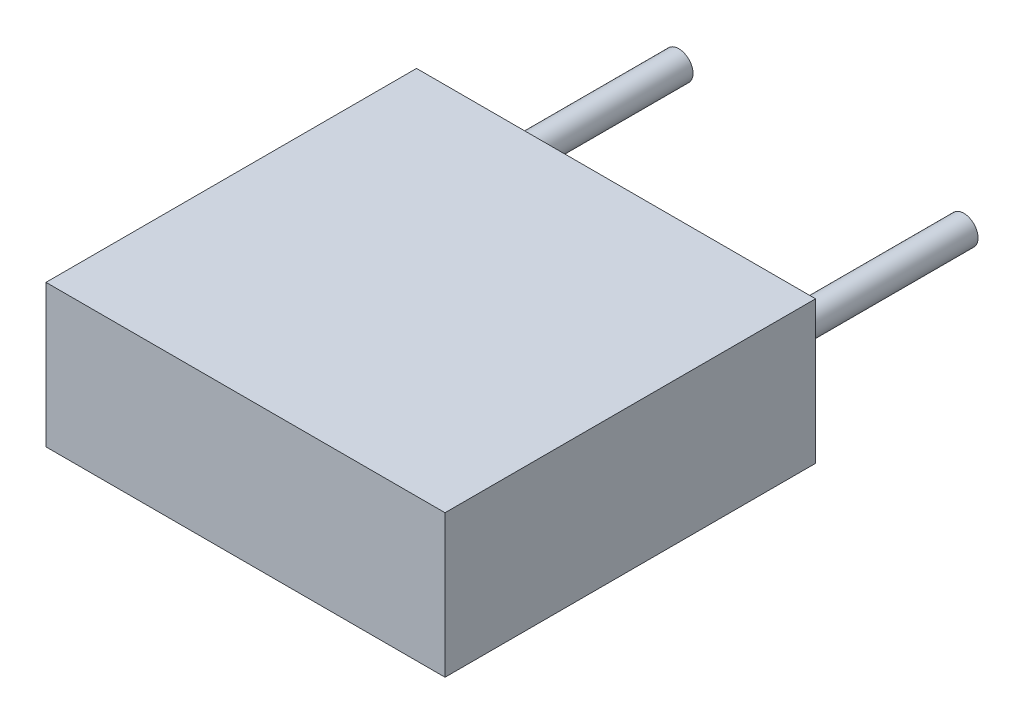
from build123d import *

# Parameters (mm, degrees)
ESQUISSE1_W        = 7
ESQUISSE1_H        = 2.5
BOSS_EXTRU_1_DEPTH = 6.5
ESQUISSE2_R        = 0.25
BOSS_EXTRU_2_DEPTH = 3.6


with BuildPart() as part:
    # Esquisse1 → Boss.-Extru.1 (new body)
    with BuildSketch(Plane.XY):
        Rectangle(ESQUISSE1_W, ESQUISSE1_H)
    extrude(amount=BOSS_EXTRU_1_DEPTH)

    # Esquisse2 → Boss.-Extru.2 (add)
    with BuildSketch(Plane(origin=(0, 0, 0), x_dir=(-1, 0, 0), z_dir=(0, 0, -1))):
        with Locations((-2.5, 0)):
            Circle(ESQUISSE2_R)
        with Locations((2.5, 0)):
            Circle(ESQUISSE2_R)
    extrude(amount=BOSS_EXTRU_2_DEPTH)


solid = part.part
